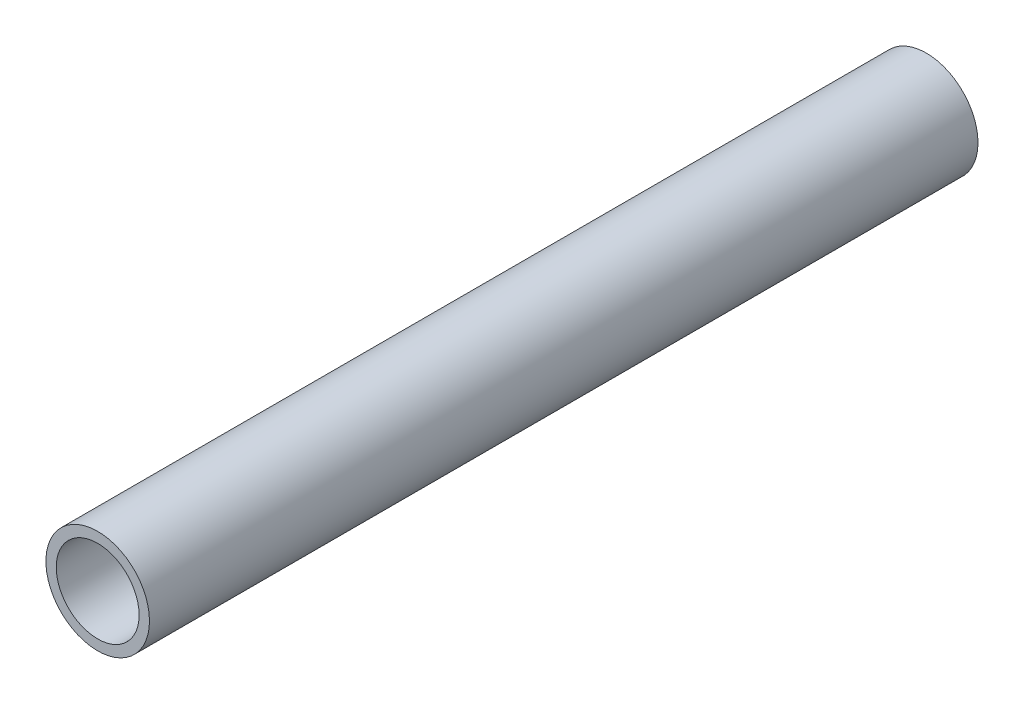
from build123d import *

# Parameters (mm, degrees)
SKETCH1_R           = 12.7
SKETCH1_R_2         = 10.16
BOSS_EXTRUDE1_DEPTH = 203.2


with BuildPart() as part:
    # Sketch1 → Boss-Extrude1 (new body)
    with BuildSketch(Plane.XY):
        Circle(SKETCH1_R)
        Circle(SKETCH1_R_2, mode=Mode.SUBTRACT)
    extrude(amount=BOSS_EXTRUDE1_DEPTH)


solid = part.part
